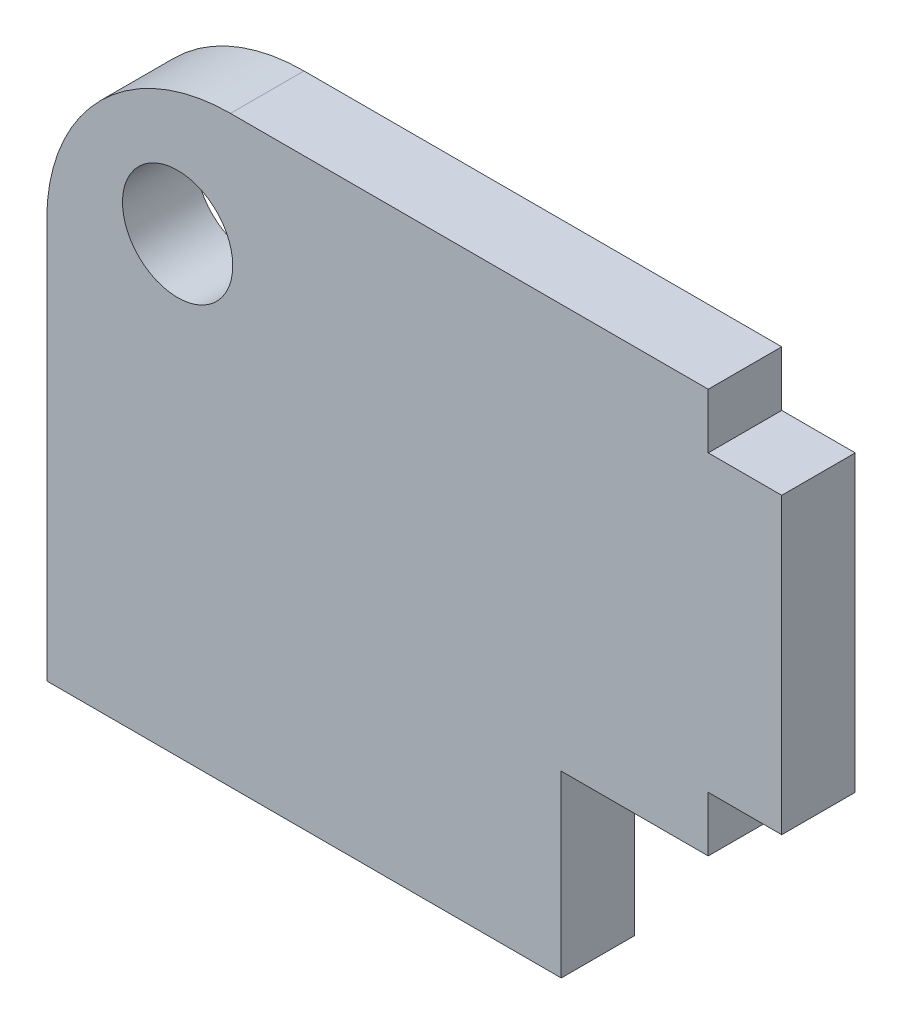
from build123d import *

# Parameters (mm, degrees)
SKETCH1_R           = 1.5
BOSS_EXTRUDE1_DEPTH = 2


with BuildPart() as part:
    # Sketch1 → Boss-Extrude1 (new body)
    with BuildSketch(Plane.XY):
        with BuildLine():
            Line((10, -1.562186701), (8, -1.562186701))
            Line((8, -1.562186701), (8, -3.062186701))
            Line((8, -3.062186701), (4, -3.062186701))
            Line((4, -3.062186701), (4, -7.937813299))
            Line((4, -7.937813299), (-10, -7.937813299))
            Line((-10, -7.937813299), (-10, 2.937813299))
            ThreePointArc((-10, 2.937813299), (-8.535533906, 6.473347205), (-5, 7.937813299))
            Line((-5, 7.937813299), (8, 7.937813299))
            Line((8, 7.937813299), (8, 6.437813299))
            Line((8, 6.437813299), (10, 6.437813299))
            Line((10, 6.437813299), (10, -1.562186701))
        make_face()
        with Locations((-6.439339828, 4.377153127)):
            Circle(SKETCH1_R, mode=Mode.SUBTRACT)
    extrude(amount=BOSS_EXTRUDE1_DEPTH)


solid = part.part
